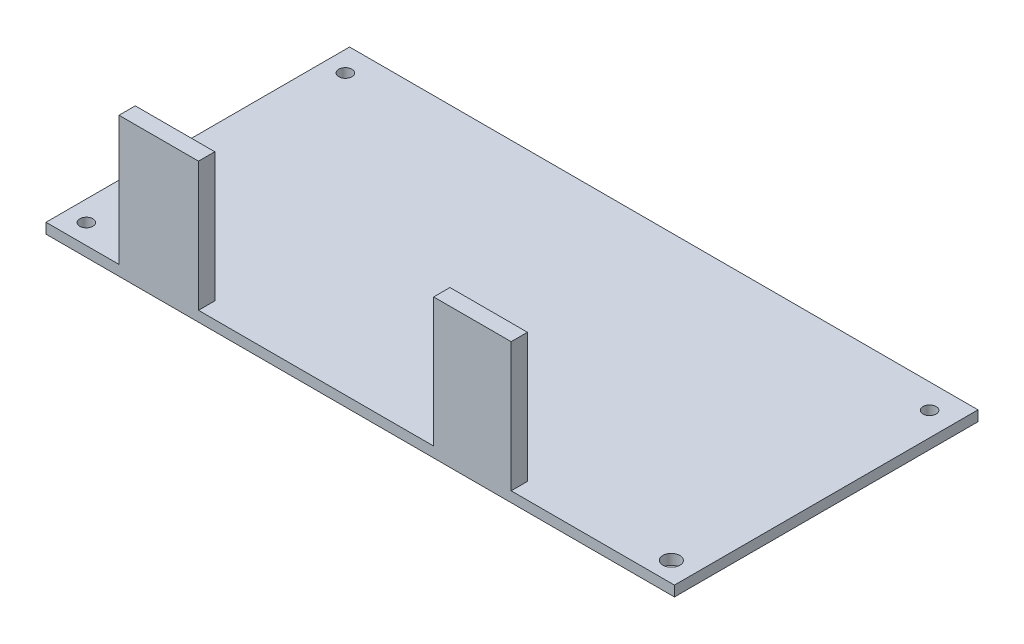
from build123d import *

# Parameters (mm, degrees)
SKETCH1_W           = 97.3
SKETCH1_H           = 47
BOSS_EXTRUDE1_DEPTH = 1.6
SKETCH2_W           = 12.310757006
SKETCH2_H           = 2.521357674
SKETCH2_W_2         = 11.997879532
BOSS_EXTRUDE2_DEPTH = 20
SKETCH3_R           = 1.016
SKETCH3_R_2         = 1.316
CUT_EXTRUDE3_DEPTH  = 2.6


with BuildPart() as part:
    # Sketch1 → Boss-Extrude1 (new body)
    with BuildSketch(Plane(origin=(0, 0, 0), x_dir=(1, 0, 0), z_dir=(0, 1, 0))):
        with Locations((48.65, -23.5)):
            Rectangle(SKETCH1_W, SKETCH1_H)
    extrude(amount=BOSS_EXTRUDE1_DEPTH)

    # Sketch2 → Boss-Extrude2 (add)
    with BuildSketch(Plane(origin=(0, 1.6, 0), x_dir=(1, 0, 0), z_dir=(0, 1, 0))):
        with Locations((17.456098962, -45.739321163)):
            Rectangle(SKETCH2_W, SKETCH2_H)
        with Locations((66.019073535, -45.739321163)):
            Rectangle(SKETCH2_W_2, SKETCH2_H)
    extrude(amount=BOSS_EXTRUDE2_DEPTH)

    # Sketch3 → Cut-Extrude3 (cut, through all)
    with BuildSketch(Plane(origin=(0, 1.6, 0), x_dir=(1, 0, 0), z_dir=(0, 1, 0))):
        with Locations((3.16, -3.81)):
            Circle(SKETCH3_R)
        with Locations((93.617, -3.81)):
            Circle(SKETCH3_R)
        with Locations((93.744, -43.916)):
            Circle(SKETCH3_R_2)
        with Locations((3.16, -43.916)):
            Circle(SKETCH3_R)
    extrude(amount=-CUT_EXTRUDE3_DEPTH, mode=Mode.SUBTRACT)


solid = part.part
